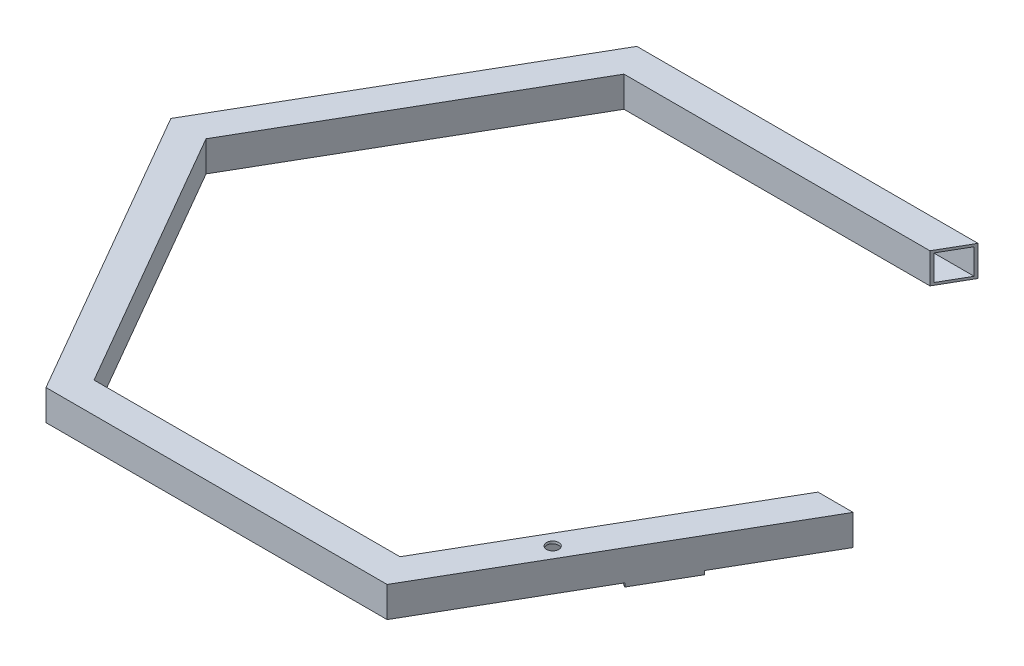
from build123d import *

# Parameters (mm, degrees)
BOSS_EXTRUDE1_DEPTH = 25
SHELL1_T            = -2
SKETCH4_R           = 5
CUT_EXTRUDE2_DEPTH  = 40
SKETCH5_R           = 5.211475532
BOSS_EXTRUDE2_DEPTH = 3
CUT_EXTRUDE3_DEPTH  = 53
BOSS_EXTRUDE3_DEPTH = 3
SKETCH8_R           = 4.596631542
CUT_EXTRUDE4_DEPTH  = 3
BOSS_EXTRUDE4_DEPTH = 3
CUT_EXTRUDE5_DEPTH  = 3
CUT_EXTRUDE6_DEPTH  = 3
CUT_EXTRUDE7_DEPTH  = 3
BOSS_EXTRUDE5_DEPTH = 3
SKETCH14_R          = 4.596631542
CUT_EXTRUDE8_DEPTH  = 23
CUT_EXTRUDE10_DEPTH = 23


with BuildPart() as part:
    # Sketch1 → Boss-Extrude1 (new body)
    with BuildSketch(Plane(origin=(0, 0, 0), x_dir=(1, 0, 0), z_dir=(0, 1, 0))):
        Polygon((125.56624327, 217.48711306), (-125.56624327, 217.48711306), (-251.132486541, 0), (-125.56624327, -217.48711306), (125.56624327, -217.48711306), (251.132486541, 0), (280, 0), (140, -242.48711306), (-140, -242.48711306), (-280, 0), (-140, 242.48711306), (140, 242.48711306), align=None)
    extrude(amount=BOSS_EXTRUDE1_DEPTH)

    # Shell1
    shell1_openings = [part.faces().sort_by_distance(p)[0] for p in [
        (265.56624327, 12.5, 0),
        (132.783121635, 12.5, -229.98711306),
    ]]
    offset(amount=SHELL1_T, openings=shell1_openings, kind=Kind.INTERSECTION)

    # Sketch4 → Cut-Extrude2 (cut)
    with BuildSketch(Plane(origin=(0, 25, 0), x_dir=(1, 0, 0), z_dir=(0, 1, 0))):
        with Locations((180.587500524, -147.1875)):
            Circle(SKETCH4_R)
    extrude(amount=-CUT_EXTRUDE2_DEPTH, mode=Mode.SUBTRACT)

    # Sketch5 → Boss-Extrude2 (add)
    with BuildSketch(Plane(origin=(0, 25, 0), x_dir=(1, 0, 0), z_dir=(0, 1, 0))):
        Polygon((201.132486541, -86.602540378), (159.222437422, -159.192874799), (98.600659157, -124.192874799), (140.510708276, -51.602540378), align=None)
        with Locations((121.228675973, -125)):
            Circle(SKETCH5_R, mode=Mode.SUBTRACT)
    extrude(amount=-BOSS_EXTRUDE2_DEPTH)

    # Sketch6 → Cut-Extrude3 (cut)
    with BuildSketch(Plane(origin=(0, 25, 0), x_dir=(1, 0, 0), z_dir=(0, 1, 0))):
        Polygon((140.510708276, -51.602540378), (201.132486541, -86.602540378), (158.682929972, -160.127329114), (98.061151707, -125.127329114), align=None)
    extrude(amount=-CUT_EXTRUDE3_DEPTH, mode=Mode.SUBTRACT)

    # Sketch7 → Boss-Extrude3 (add)
    with BuildSketch(Plane(origin=(0, 25, 0), x_dir=(1, 0, 0), z_dir=(0, 1, 0))):
        Polygon((227.297559203, -41.283305143), (205.297559203, -79.388422909), (149.005907957, -46.888422909), (171.005907957, -8.783305143), align=None)
    extrude(amount=-BOSS_EXTRUDE3_DEPTH)

    # Sketch8 → Cut-Extrude4 (cut)
    with BuildSketch(Plane(origin=(0, 25, 0), x_dir=(1, 0, 0), z_dir=(0, 1, 0))):
        with Locations((196.32303906, -78.932747771)):
            Circle(SKETCH8_R)
    extrude(amount=-CUT_EXTRUDE4_DEPTH, mode=Mode.SUBTRACT)

    # Sketch9 → Boss-Extrude4 (add)
    with BuildSketch(Plane(origin=(0, 25, 0), x_dir=(1, 0, 0), z_dir=(0, 1, 0))):
        with BuildLine():
            Line((205.297559203, -79.388422909), (200.181682496, -76.434770115))
            ThreePointArc((200.181682496, -76.434770115), (194.024723289, -82.913547458), (196.55702945, -74.342075704))
            Line((196.55702945, -74.342075704), (149.005907957, -46.888422909))
            Line((149.005907957, -46.888422909), (138.101240513, -65.775860963))
            Line((138.101240513, -65.775860963), (194.392891759, -98.275860963))
            Line((194.392891759, -98.275860963), (205.297559203, -79.388422909))
        make_face()
    extrude(amount=-BOSS_EXTRUDE4_DEPTH)

    # Sketch10 → Cut-Extrude5 (cut)
    with BuildSketch(Plane(origin=(0, 25, 0), x_dir=(1, 0, 0), z_dir=(0, 1, 0))):
        Polygon((171.005907957, -8.783305143), (227.297559203, -41.283305143), (211.247303055, -69.083164267), (154.955651809, -36.583164267), align=None)
    extrude(amount=-CUT_EXTRUDE5_DEPTH, mode=Mode.SUBTRACT)

    # Sketch11 → Cut-Extrude6 (cut)
    with BuildSketch(Plane(origin=(0, 25, 0), x_dir=(1, 0, 0), z_dir=(0, 1, 0))):
        Polygon((154.955651809, -36.583164267), (189.376099165, -56.455818813), (172.628994903, -85.462654274), (138.208547547, -65.589999728), align=None)
    extrude(amount=-CUT_EXTRUDE6_DEPTH, mode=Mode.SUBTRACT)

    # Sketch12 → Cut-Extrude7 (cut)
    with BuildSketch(Plane(origin=(0, 25, 0), x_dir=(1, 0, 0), z_dir=(0, 1, 0))):
        Polygon((133.472959546, -64.327583033), (137.505827692, -57.317833183), (175.943359627, -79.431817482), (171.910491481, -86.441567333), align=None)
    extrude(amount=-CUT_EXTRUDE7_DEPTH, mode=Mode.SUBTRACT)

    # Sketch13 → Boss-Extrude5 (add)
    with BuildSketch(Plane.XZ):
        Polygon((197.947448943, 92.119187322), (189.768280461, 106.285922696), (211.418915556, 118.785922696), (235.385066588, 77.275331446), (213.403041068, 64.584003094), (211.247303055, 69.083164267), (189.376099165, 56.455818813), (176.035335717, 79.351557189), align=None)
    extrude(amount=BOSS_EXTRUDE5_DEPTH)

    # Sketch14 → Cut-Extrude8 (cut)
    with BuildSketch(Plane(origin=(0, 0, 0), x_dir=(1, 0, 0), z_dir=(0, 1, 0))):
        with Locations((192.705001821, -81.222810357)):
            Circle(SKETCH14_R)
    extrude(amount=-CUT_EXTRUDE8_DEPTH, mode=Mode.SUBTRACT)

    # Sketch15 → Cut-Extrude10 (cut)
    with BuildSketch(Plane(origin=(0, 25, 0), x_dir=(1, 0, 0), z_dir=(0, 1, 0))):
        Polygon((187.452678382, -55.345331307), (211.247303055, -69.083164267), (194.392891759, -98.275860963), (170.321525229, -84.378251017), align=None)
    extrude(amount=-CUT_EXTRUDE10_DEPTH, mode=Mode.SUBTRACT)


solid = part.part
